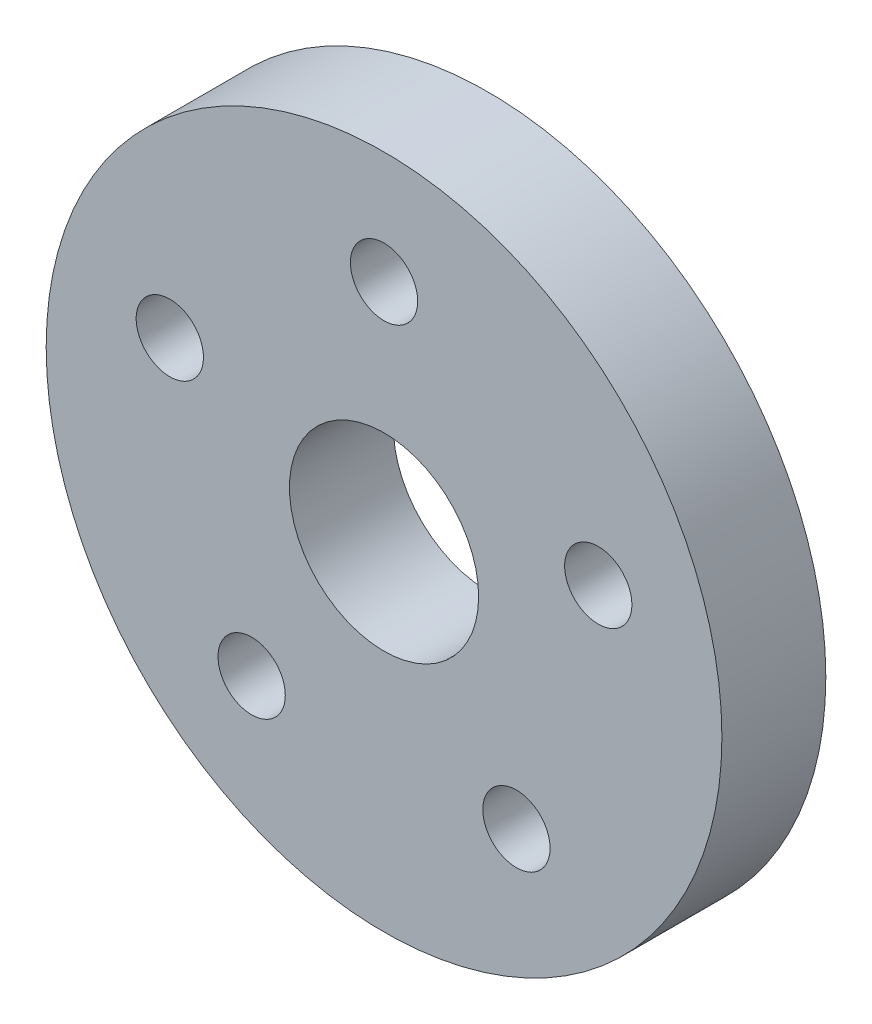
from build123d import *

# Parameters (mm, degrees)
SKETCH1_R           = 14.2875
SKETCH1_R_2         = 4
SKETCH1_R_3         = 1.4224
BOSS_EXTRUDE1_DEPTH = 4.3942


with BuildPart() as part:
    # Sketch1 → Boss-Extrude1 (new body)
    with BuildSketch(Plane.XY):
        Circle(SKETCH1_R)
        Circle(SKETCH1_R_2, mode=Mode.SUBTRACT)
        with Locations((0, 9.525)):
            Circle(SKETCH1_R_3, mode=Mode.SUBTRACT)
        with Locations((9.058813318, 2.943386871)):
            Circle(SKETCH1_R_3, mode=Mode.SUBTRACT)
        with Locations((5.598654528, -7.705886871)):
            Circle(SKETCH1_R_3, mode=Mode.SUBTRACT)
        with Locations((-5.598654528, -7.705886871)):
            Circle(SKETCH1_R_3, mode=Mode.SUBTRACT)
        with Locations((-9.058813318, 2.943386871)):
            Circle(SKETCH1_R_3, mode=Mode.SUBTRACT)
    extrude(amount=BOSS_EXTRUDE1_DEPTH)


solid = part.part
